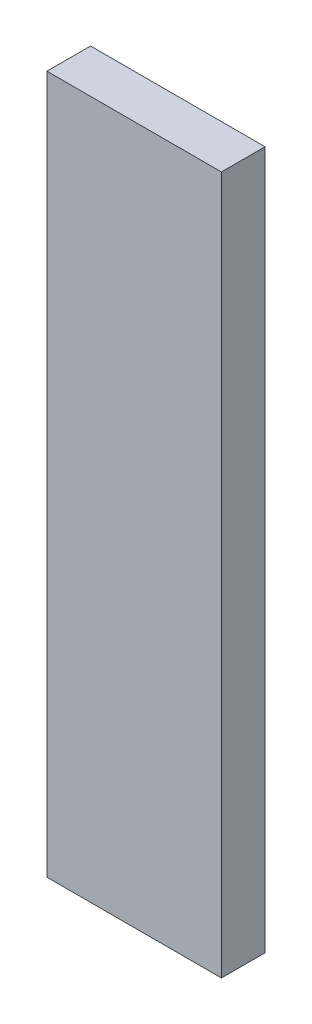
from build123d import *

# Parameters (mm, degrees)
SKETCH1_W           = 50.8
SKETCH1_H           = 203.2
BOSS_EXTRUDE1_DEPTH = 12.7


with BuildPart() as part:
    # Sketch1 → Boss-Extrude1 (new body)
    with BuildSketch(Plane.XY):
        with Locations((25.4, 101.6)):
            Rectangle(SKETCH1_W, SKETCH1_H)
    extrude(amount=BOSS_EXTRUDE1_DEPTH)


solid = part.part
